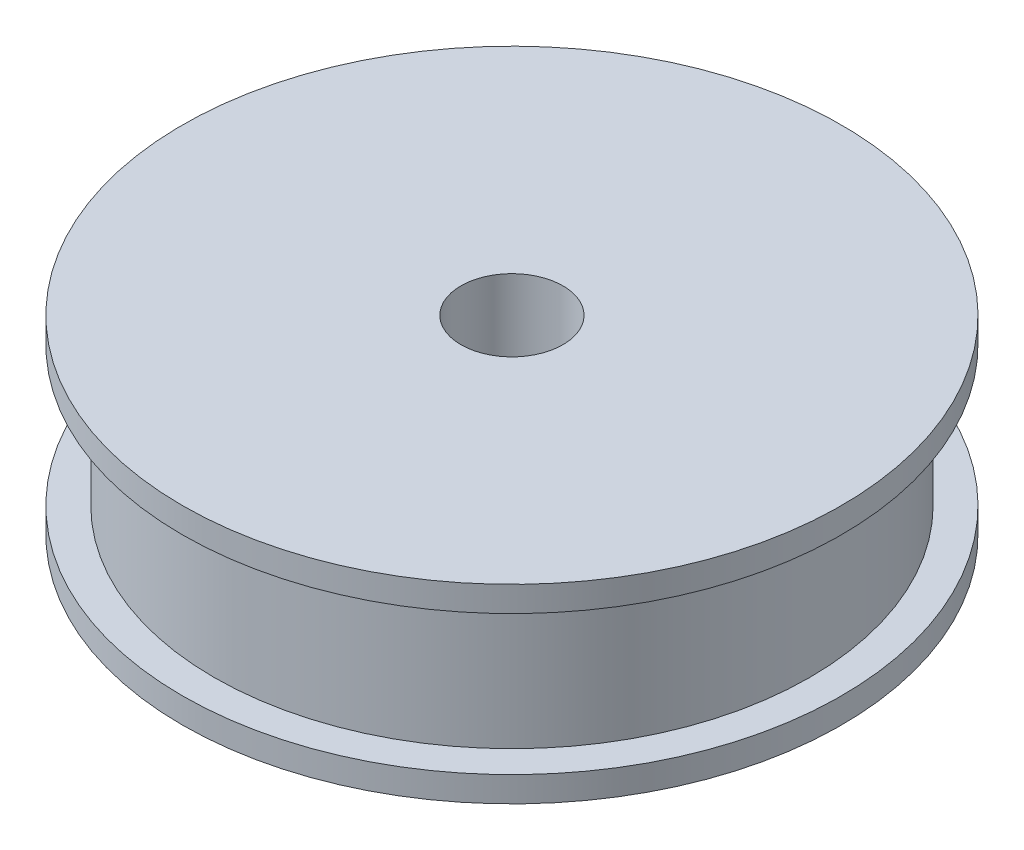
from build123d import *

# Parameters (mm, degrees)
SKETCH_1_R          = 26
EXTRUDE_1_DEPTH     = 2
SKETCH_2_R          = 23.495
EXTRUDE_2_DEPTH     = 11
SKETCH_3_R          = 26
EXTRUDE_3_DEPTH     = 2
SKETCH_4_R          = 4.025
CUT_EXTRUDE_1_DEPTH = 16


with BuildPart() as part:
    # 草图1 → 凸台-拉伸1 (new body)
    with BuildSketch(Plane(origin=(0, 0, 0), x_dir=(1, 0, 0), z_dir=(0, 1, 0))):
        Circle(SKETCH_1_R)
    extrude(amount=EXTRUDE_1_DEPTH)

    # 草图2 → 凸台-拉伸2 (add)
    with BuildSketch(Plane(origin=(0, 2, 0), x_dir=(1, 0, 0), z_dir=(0, 1, 0))):
        Circle(SKETCH_2_R)
    extrude(amount=EXTRUDE_2_DEPTH)

    # 草图3 → 凸台-拉伸3 (add)
    with BuildSketch(Plane(origin=(0, 13, 0), x_dir=(1, 0, 0), z_dir=(0, 1, 0))):
        Circle(SKETCH_3_R)
    extrude(amount=EXTRUDE_3_DEPTH)

    # 草图4 → 切除-拉伸1 (cut, through all)
    with BuildSketch(Plane(origin=(0, 15, 0), x_dir=(1, 0, 0), z_dir=(0, 1, 0))):
        Circle(SKETCH_4_R)
    extrude(amount=-CUT_EXTRUDE_1_DEPTH, mode=Mode.SUBTRACT)


solid = part.part
